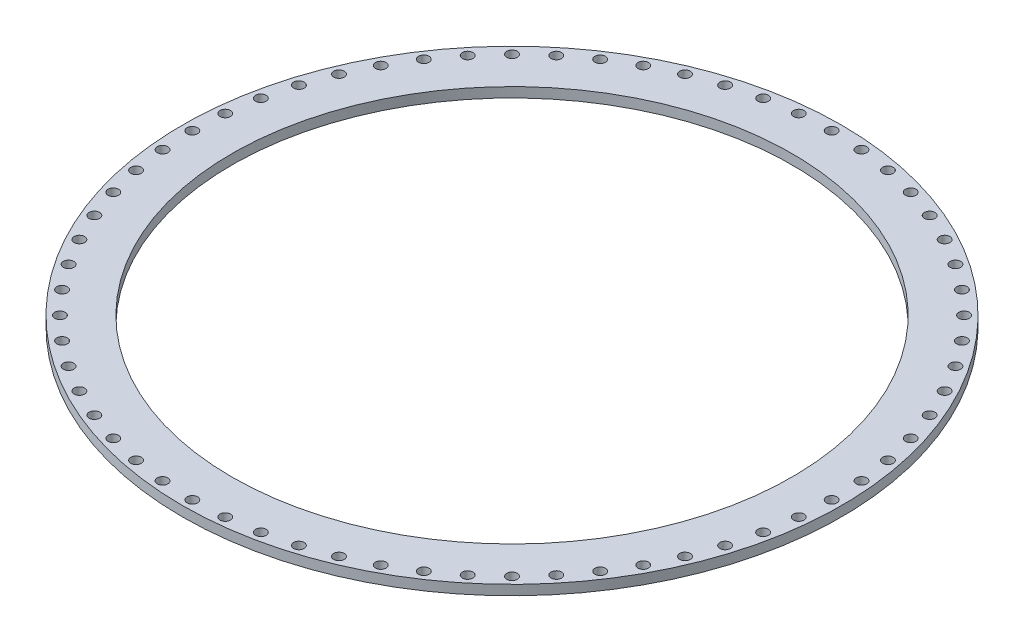
from build123d import *

# Parameters (mm, degrees)
ESQUISSE2_W                  = 100
ESQUISSE2_H                  = 3
ESQUISSE4_R                  = 85
CENTRALHOLE_DEPTH            = 4
ESQUISSE5_R                  = 1.6
FIXINGHOLE_DEPTH             = 4
R_P_TITION_CIRCULAIRE1_COUNT = 64


with BuildPart() as part:
    # Esquisse2 → MainRevolution (revolve)
    with BuildSketch(Plane.XY):
        with Locations((50, 1.5)):
            Rectangle(ESQUISSE2_W, ESQUISSE2_H)
    revolve(axis=Axis((0, 55, 0), (0, -1, 0)))

    # Esquisse4 → CentralHole (cut, through all)
    with BuildSketch(Plane(origin=(0, 3, 0), x_dir=(1, 0, 0), z_dir=(0, 1, 0))):
        Circle(ESQUISSE4_R)
    extrude(amount=-CENTRALHOLE_DEPTH, mode=Mode.SUBTRACT)

    # Esquisse5 → FixingHole (cut, through all)
    with BuildSketch(Plane(origin=(0, 3, 0), x_dir=(1, 0, 0), z_dir=(0, 1, 0))):
        with Locations((97, 0)):
            Circle(ESQUISSE5_R)
    fixinghole = extrude(amount=-FIXINGHOLE_DEPTH, mode=Mode.SUBTRACT)

    # Répétition circulaire1: FixingHole ×64 about axis
    r_p_tition_circulaire1_axis = Axis((0, 0, 0), (0, 1, 0))
    for i in range(1, R_P_TITION_CIRCULAIRE1_COUNT):
        add(fixinghole.rotate(r_p_tition_circulaire1_axis, i * 360 / R_P_TITION_CIRCULAIRE1_COUNT), mode=Mode.SUBTRACT)


solid = part.part
